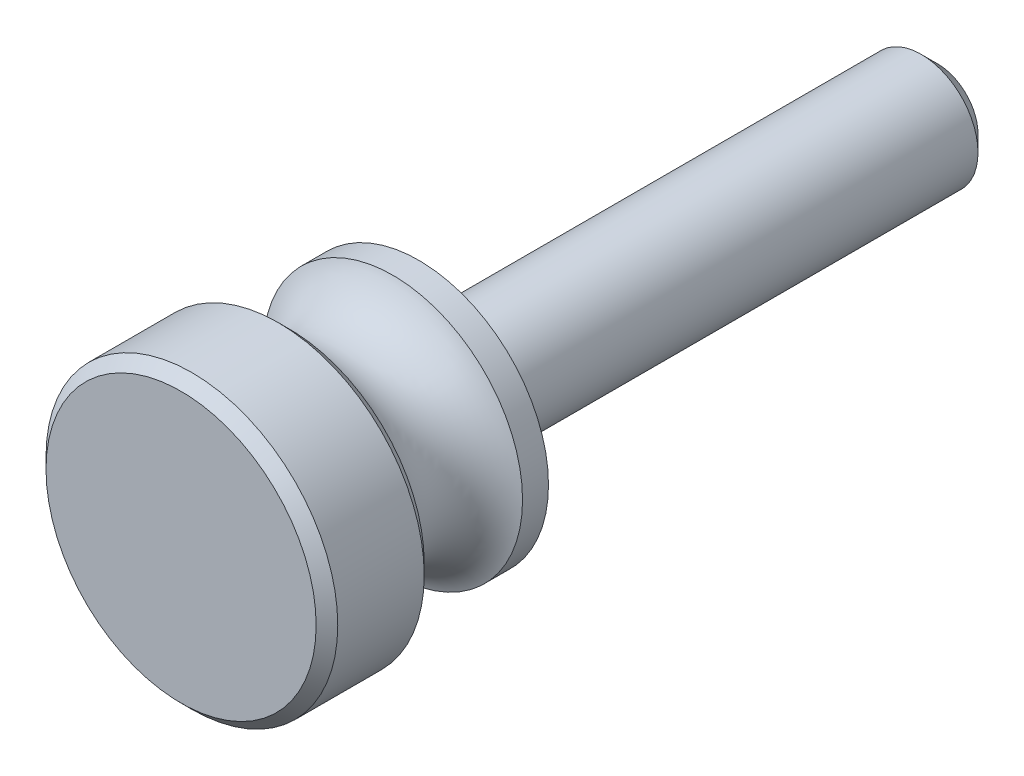
from build123d import *

# Parameters (mm, degrees)
SKETCH1_R           = 2.0828
EXTRUDE1_DEPTH      = 19.05
CHAMFER2_SIZE       = 0.5953125
SKETCH27_R          = 4.7625
BOSS_EXTRUDE4_DEPTH = 4.7625
SKETCH21_R          = 5.3578125
BOSS_EXTRUDE1_DEPTH = 3.96875
CHAMFER3_SIZE       = 0.396875


with BuildPart() as part:
    # Sketch1 → Extrude1 (new body)
    with BuildSketch(Plane.XY):
        Circle(SKETCH1_R)
    extrude(amount=-EXTRUDE1_DEPTH)

    # Chamfer2
    chamfer2_edges = [part.edges().sort_by_distance(p)[0] for p in [
        (-2.0828, 0, -19.05),
    ]]
    chamfer(chamfer2_edges, length=CHAMFER2_SIZE)

    # Sketch27 → Boss-Extrude4 (add)
    with BuildSketch(Plane.XY):
        Circle(SKETCH27_R)
    extrude(amount=BOSS_EXTRUDE4_DEPTH)

    # Sketch21 → Boss-Extrude1 (add)
    with BuildSketch(Plane.XY.offset(4.7625)):
        Circle(SKETCH21_R)
    extrude(amount=BOSS_EXTRUDE1_DEPTH)

    # Sketch28 → Cut-Revolve1 (revolve, cut)
    with BuildSketch(Plane(origin=(0, 0, 0), x_dir=(0, 0, -1), z_dir=(1, 0, 0))):
        with BuildLine():
            Line((-4.7625, 4.7625), (-0.9525, 4.7625))
            ThreePointArc((-0.9525, 4.7625), (-2.8575, 3.442334108), (-4.7625, 4.7625))
        make_face()
    revolve(axis=Axis((0, 0, 0), (0, 0, -1)), mode=Mode.SUBTRACT)

    # Chamfer3
    chamfer3_edges = [part.edges().sort_by_distance(p)[0] for p in [
        (-5.3578125, 0, 4.7625),
        (-5.3578125, 0, 8.73125),
    ]]
    chamfer(chamfer3_edges, length=CHAMFER3_SIZE)


solid = part.part
